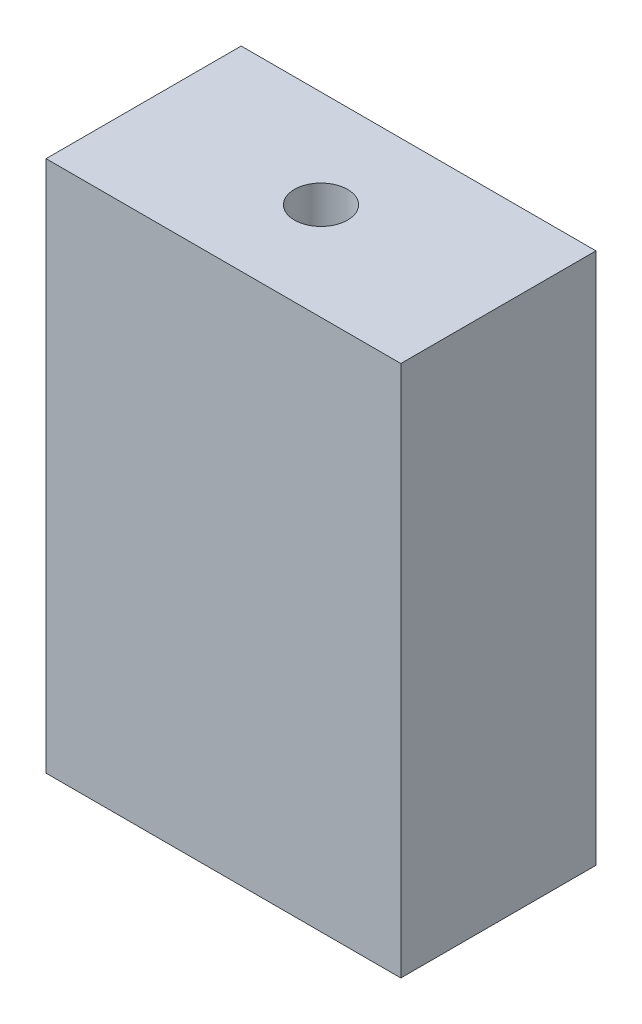
from build123d import *

# Parameters (mm, degrees)
SKETCH1_W           = 20
SKETCH1_H           = 20
SKETCH1_R           = 8
FIRSTLAYER_DEPTH    = 5
SKETCH2_W           = 20
SKETCH2_H           = 20
SKETCH2_R           = 6
SECONDLAYER_DEPTH   = 0.5
SKETCH3_W           = 20
SKETCH3_H           = 20
THIRDLAYER_DEPTH    = 5.5
SKETCH4_W           = 20
SKETCH4_H           = 11
BOSS_EXTRUDE4_DEPTH = 10
SKETCH10_W          = 5.42
SKETCH10_H          = 2.36
NUT_HOLE_DEPTH      = 5.5
NUT_HOLE_DEPTH_BACK = 2.71
SKETCH11_R          = 1.5
SCREW_HOLE_DEPTH    = 5.64


with BuildPart() as part:
    # Sketch1 → FirstLayer (new body)
    with BuildSketch(Plane.XY):
        Rectangle(SKETCH1_W, SKETCH1_H)
        Circle(SKETCH1_R, mode=Mode.SUBTRACT)
    extrude(amount=-FIRSTLAYER_DEPTH)

    # Sketch2 → SecondLayer (add)
    with BuildSketch(Plane.XY):
        Rectangle(SKETCH2_W, SKETCH2_H)
        Circle(SKETCH2_R, mode=Mode.SUBTRACT)
    extrude(amount=SECONDLAYER_DEPTH)

    # Sketch3 → ThirdLayer (add)
    with BuildSketch(Plane.XY.offset(0.5)):
        Rectangle(SKETCH3_W, SKETCH3_H)
    extrude(amount=THIRDLAYER_DEPTH)

    # Sketch4 → Boss-Extrude4 (add)
    with BuildSketch(Plane(origin=(0, 10, 0), x_dir=(1, 0, 0), z_dir=(0, 1, 0))):
        with Locations((0, -0.5)):
            Rectangle(SKETCH4_W, SKETCH4_H)
    extrude(amount=BOSS_EXTRUDE4_DEPTH)

    # Sketch10 → Nut Hole (cut, two sides)
    with BuildSketch(Plane(origin=(0, 0, 0.5), x_dir=(-1, 0, 0), z_dir=(0, 0, -1))) as nut_hole_sk:
        with Locations((0, 13.18)):
            Rectangle(SKETCH10_W, SKETCH10_H)
    extrude(amount=NUT_HOLE_DEPTH, mode=Mode.SUBTRACT)
    extrude(nut_hole_sk.sketch, amount=-NUT_HOLE_DEPTH_BACK, mode=Mode.SUBTRACT)

    # Sketch11 → Screw Hole (cut)
    with BuildSketch(Plane(origin=(0, 20, 0), x_dir=(1, 0, 0), z_dir=(0, 1, 0))):
        with Locations((0, -0.5)):
            Circle(SKETCH11_R)
    extrude(amount=-SCREW_HOLE_DEPTH, mode=Mode.SUBTRACT)


solid = part.part
